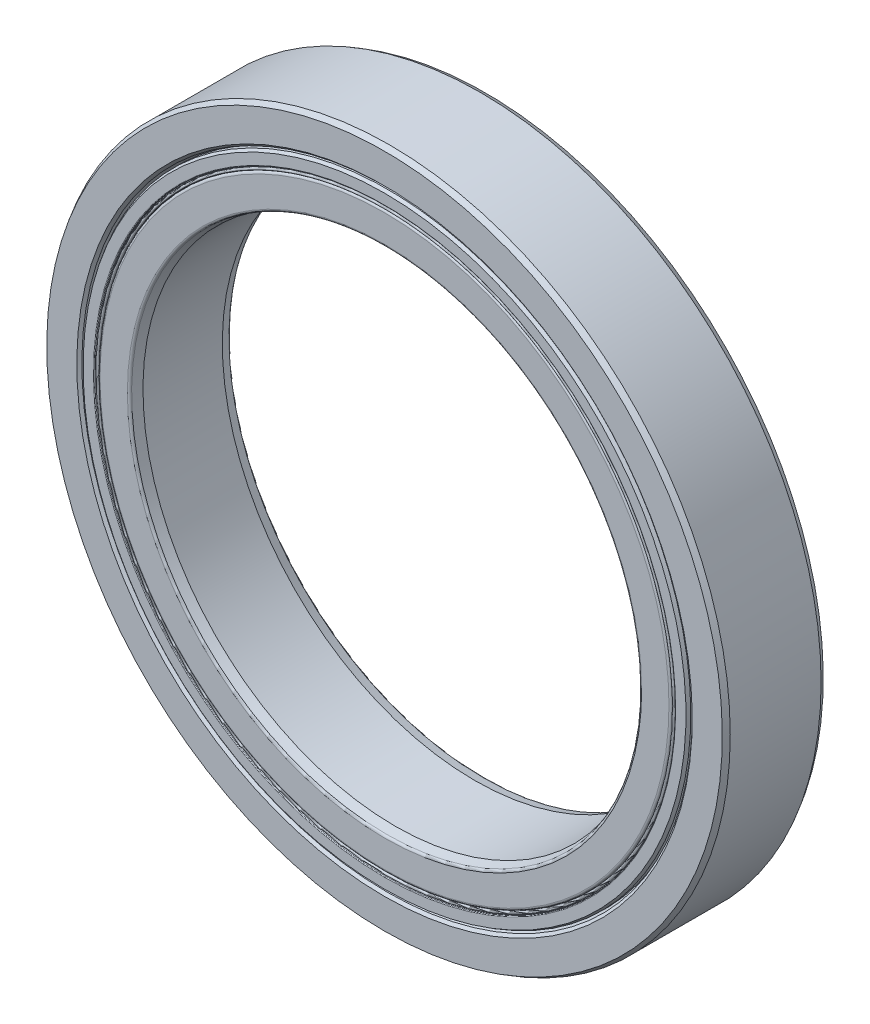
from build123d import *

# Parameters (mm, degrees)
CIRPATTERN1_COUNT = 18


with BuildPart() as part:
    # Sketch3 → Revolve1 (revolve)
    with BuildSketch(Plane(origin=(0, 0, 0), x_dir=(0, 0, -1), z_dir=(1, 0, 0))):
        with BuildLine():
            Line((-1.682987285, 12.015), (-1.9, 12.093986169))
            Line((-1.9, 12.093986169), (-2, 12.193986169))
            Line((-2, 12.193986169), (-2, 13.384529946))
            Line((-2, 13.384529946), (-1.8, 13.5))
            Line((-1.8, 13.5), (1.8, 13.5))
            Line((1.8, 13.5), (2, 13.384529946))
            Line((2, 13.384529946), (2, 12.193986169))
            Line((2, 12.193986169), (1.9, 12.093986169))
            Line((1.9, 12.093986169), (1.682987285, 12.015))
            Line((1.682987285, 12.015), (1.272261766, 12.015))
            ThreePointArc((1.272261766, 12.015), (0, 13.005), (-1.272261766, 12.015))
            Line((-1.272261766, 12.015), (-1.682987285, 12.015))
        make_face()
    revolve(axis=Axis((0, 0, 2), (0, 0, -1)))


with BuildPart() as body_2:
    # Sketch4 → Revolve2 (revolve)
    with BuildSketch(Plane(origin=(0, 0, 0), x_dir=(0, 0, -1), z_dir=(1, 0, 0))):
        with BuildLine():
            Line((-1.572559109, 10), (-1.927103936, 10.095))
            ThreePointArc((-1.927103936, 10.095), (-1.979676045, 10.13012756), (-2, 10.19))
            Line((-2, 10.19), (-2, 11.271648763))
            ThreePointArc((-2, 11.271648763), (-1.97119359, 11.34119359), (-1.901648763, 11.37))
            Line((-1.901648763, 11.37), (-1.272261766, 11.37))
            ThreePointArc((-1.272261766, 11.37), (0, 10.38), (1.272261766, 11.37))
            Line((1.272261766, 11.37), (1.901648763, 11.37))
            ThreePointArc((1.901648763, 11.37), (1.97119359, 11.34119359), (2, 11.271648763))
            Line((2, 11.271648763), (2, 10.19))
            ThreePointArc((2, 10.19), (1.979676045, 10.13012756), (1.927103936, 10.095))
            Line((1.927103936, 10.095), (1.572559109, 10))
            Line((1.572559109, 10), (-1.572559109, 10))
        make_face()
    revolve(axis=Axis((0, 0, 2), (0, 0, -1)))


with BuildPart() as body_3:
    # Sketch5 → Revolve3 (revolve)
    with BuildSketch(Plane(origin=(0, 0, 0), x_dir=(0, 0, -1), z_dir=(1, 0, 0))):
        with BuildLine():
            Line((-1.3125, 11.6925), (1.3125, 11.6925))
            ThreePointArc((1.3125, 11.6925), (0, 13.005), (-1.3125, 11.6925))
        make_face()
    revolve(axis=Axis((0, 11.6925, 1.3125), (0, 0, -1)))


with BuildPart() as cirpattern1_1:
    # CirPattern1: pattern copy
    add(body_3.part.rotate(Axis((0, 0, 0), (0, 0, 1)), 1 * 360 / CIRPATTERN1_COUNT))


with BuildPart() as cirpattern1_2:
    # CirPattern1: pattern copy
    add(body_3.part.rotate(Axis((0, 0, 0), (0, 0, 1)), 2 * 360 / CIRPATTERN1_COUNT))


with BuildPart() as cirpattern1_3:
    # CirPattern1: pattern copy
    add(body_3.part.rotate(Axis((0, 0, 0), (0, 0, 1)), 3 * 360 / CIRPATTERN1_COUNT))


with BuildPart() as cirpattern1_4:
    # CirPattern1: pattern copy
    add(body_3.part.rotate(Axis((0, 0, 0), (0, 0, 1)), 4 * 360 / CIRPATTERN1_COUNT))


with BuildPart() as cirpattern1_5:
    # CirPattern1: pattern copy
    add(body_3.part.rotate(Axis((0, 0, 0), (0, 0, 1)), 5 * 360 / CIRPATTERN1_COUNT))


with BuildPart() as cirpattern1_6:
    # CirPattern1: pattern copy
    add(body_3.part.rotate(Axis((0, 0, 0), (0, 0, 1)), 6 * 360 / CIRPATTERN1_COUNT))


with BuildPart() as cirpattern1_7:
    # CirPattern1: pattern copy
    add(body_3.part.rotate(Axis((0, 0, 0), (0, 0, 1)), 7 * 360 / CIRPATTERN1_COUNT))


with BuildPart() as cirpattern1_8:
    # CirPattern1: pattern copy
    add(body_3.part.rotate(Axis((0, 0, 0), (0, 0, 1)), 8 * 360 / CIRPATTERN1_COUNT))


with BuildPart() as cirpattern1_9:
    # CirPattern1: pattern copy
    add(body_3.part.rotate(Axis((0, 0, 0), (0, 0, 1)), 9 * 360 / CIRPATTERN1_COUNT))


with BuildPart() as cirpattern1_10:
    # CirPattern1: pattern copy
    add(body_3.part.rotate(Axis((0, 0, 0), (0, 0, 1)), 10 * 360 / CIRPATTERN1_COUNT))


with BuildPart() as cirpattern1_11:
    # CirPattern1: pattern copy
    add(body_3.part.rotate(Axis((0, 0, 0), (0, 0, 1)), 11 * 360 / CIRPATTERN1_COUNT))


with BuildPart() as cirpattern1_12:
    # CirPattern1: pattern copy
    add(body_3.part.rotate(Axis((0, 0, 0), (0, 0, 1)), 12 * 360 / CIRPATTERN1_COUNT))


with BuildPart() as cirpattern1_13:
    # CirPattern1: pattern copy
    add(body_3.part.rotate(Axis((0, 0, 0), (0, 0, 1)), 13 * 360 / CIRPATTERN1_COUNT))


with BuildPart() as cirpattern1_14:
    # CirPattern1: pattern copy
    add(body_3.part.rotate(Axis((0, 0, 0), (0, 0, 1)), 14 * 360 / CIRPATTERN1_COUNT))


with BuildPart() as cirpattern1_15:
    # CirPattern1: pattern copy
    add(body_3.part.rotate(Axis((0, 0, 0), (0, 0, 1)), 15 * 360 / CIRPATTERN1_COUNT))


with BuildPart() as cirpattern1_16:
    # CirPattern1: pattern copy
    add(body_3.part.rotate(Axis((0, 0, 0), (0, 0, 1)), 16 * 360 / CIRPATTERN1_COUNT))


with BuildPart() as cirpattern1_17:
    # CirPattern1: pattern copy
    add(body_3.part.rotate(Axis((0, 0, 0), (0, 0, 1)), 17 * 360 / CIRPATTERN1_COUNT))


with BuildPart() as body_21:
    # Sketch6 → Revolve4 (revolve)
    with BuildSketch(Plane(origin=(0, 0, 0), x_dir=(0, 0, -1), z_dir=(1, 0, 0))):
        with BuildLine():
            Line((-1.878756443, 12.015), (-1.3125, 12.015))
            Line((-1.3125, 12.015), (-1.3125, 11.51))
            Line((-1.3125, 11.51), (-1.972, 11.51))
            ThreePointArc((-1.972, 11.51), (-1.99179899, 11.51820101), (-2, 11.538))
            Line((-2, 11.538), (-2, 11.945))
            Line((-2, 11.945), (-1.878756443, 12.015))
        make_face()
        with BuildLine():
            Line((1.972, 11.51), (1.3125, 11.51))
            Line((1.3125, 11.51), (1.3125, 12.015))
            Line((1.3125, 12.015), (1.878756443, 12.015))
            Line((1.878756443, 12.015), (2, 11.945))
            Line((2, 11.945), (2, 11.538))
            ThreePointArc((2, 11.538), (1.99179899, 11.51820101), (1.972, 11.51))
        make_face()
    revolve(axis=Axis((0, 0, 2), (0, 0, -1)))


with BuildPart() as body_22:
    # Sketch7 → Revolve5 (revolve)
    with BuildSketch(Plane(origin=(0, 0, 0), x_dir=(0, 0, -1), z_dir=(1, 0, 0))):
        with BuildLine():
            Line((-1.3125, 11.51), (-1.890562103, 11.51))
            Line((-1.890562103, 11.51), (-1.925030375, 11.503922314))
            ThreePointArc((-1.925030375, 11.503922314), (-1.937016396, 11.488301826), (-1.9225, 11.475))
            Line((-1.9225, 11.475), (-1.9475, 11.475))
            ThreePointArc((-1.9475, 11.475), (-2, 11.4225), (-1.9475, 11.37))
            Line((-1.9475, 11.37), (-1.3125, 11.37))
            Line((-1.3125, 11.37), (-1.3125, 11.51))
        make_face()
    revolve(axis=Axis((0, 0, 2), (0, 0, -1)))


solid = Compound([part.part, body_2.part, body_3.part, cirpattern1_1.part, cirpattern1_2.part, cirpattern1_3.part, cirpattern1_4.part, cirpattern1_5.part, cirpattern1_6.part, cirpattern1_7.part, cirpattern1_8.part, cirpattern1_9.part, cirpattern1_10.part, cirpattern1_11.part, cirpattern1_12.part, cirpattern1_13.part, cirpattern1_14.part, cirpattern1_15.part, cirpattern1_16.part, cirpattern1_17.part, body_21.part, body_22.part])
